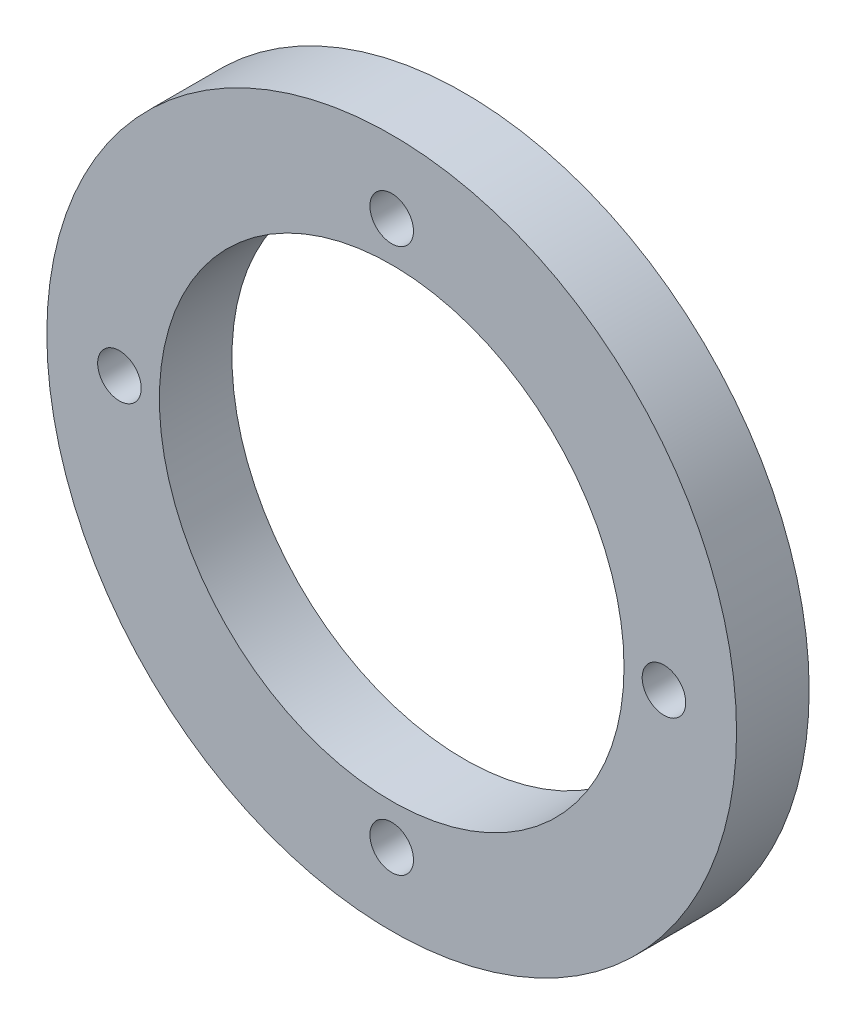
from build123d import *

# Parameters (mm, degrees)
ESQUISSE1_R        = 4.75
ESQUISSE1_R_2      = 3.2
ESQUISSE1_R_3      = 0.3
BOSS_EXTRU_1_DEPTH = 1


with BuildPart() as part:
    # Esquisse1 → Boss.-Extru.1 (new body)
    with BuildSketch(Plane.XY):
        Circle(ESQUISSE1_R)
        Circle(ESQUISSE1_R_2, mode=Mode.SUBTRACT)
        with Locations((0, 3.75)):
            Circle(ESQUISSE1_R_3, mode=Mode.SUBTRACT)
        with Locations((3.75, 0)):
            Circle(ESQUISSE1_R_3, mode=Mode.SUBTRACT)
        with Locations((0, -3.75)):
            Circle(ESQUISSE1_R_3, mode=Mode.SUBTRACT)
        with Locations((-3.75, 0)):
            Circle(ESQUISSE1_R_3, mode=Mode.SUBTRACT)
    extrude(amount=BOSS_EXTRU_1_DEPTH)


solid = part.part
